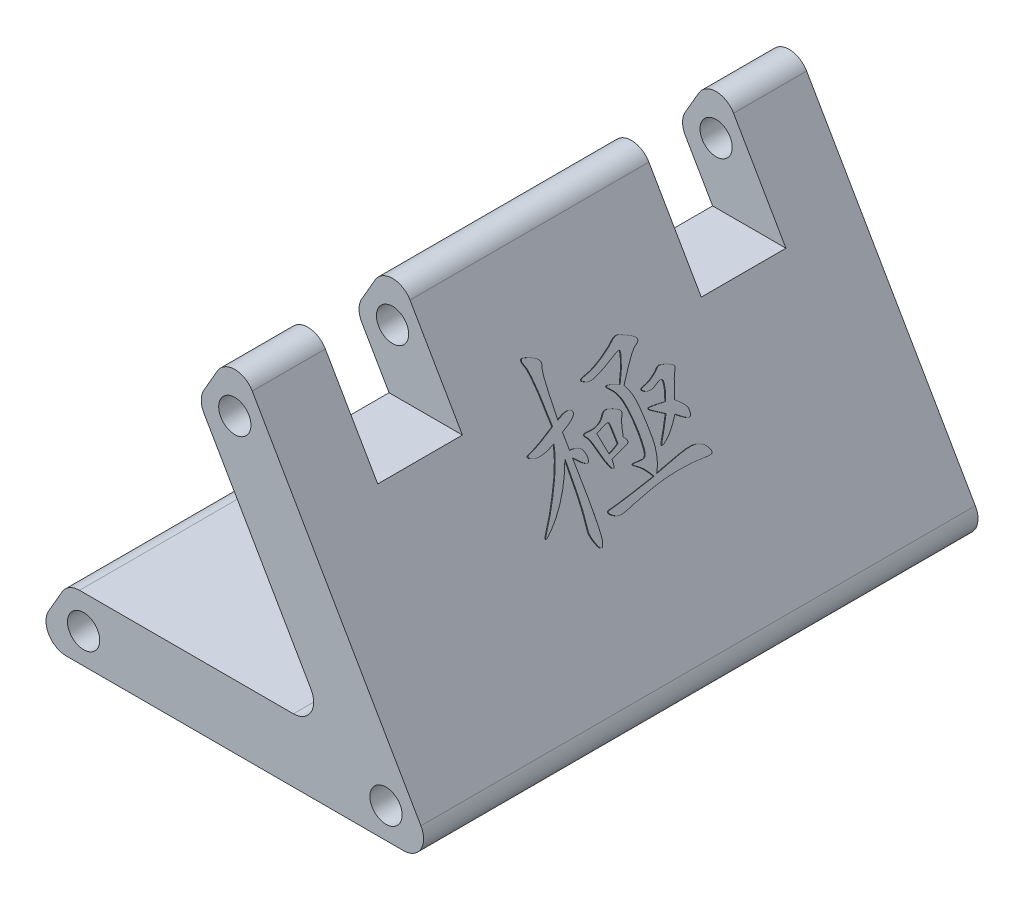
from build123d import *

# Parameters (mm, degrees)
SKETCH_1_R          = 1.6
EXTRUDE_1_DEPTH     = 27.5
FILLET_1_R          = 2
CUT_EXTRUDE_1_DEPTH = 66.5
FILLET_2_R          = 2
EXTRUDE_2_DEPTH     = 0.1
SKETCH_4_W          = 8.4
SKETCH_4_H          = 20
CUT_EXTRUDE_2_DEPTH = 25


with BuildPart() as part:
    # 草图1 → 凸台-拉伸1 (new body, symmetric)
    with BuildSketch(Plane.XY):
        Polygon((20.196152423, -28.980762114), (0, 6), (-20.196152423, -28.980762114), align=None)
        Circle(SKETCH_1_R, mode=Mode.SUBTRACT)
        with Locations((-15, -25.980762114)):
            Circle(SKETCH_1_R, mode=Mode.SUBTRACT)
        with Locations((15, -25.980762114)):
            Circle(SKETCH_1_R, mode=Mode.SUBTRACT)
    extrude(amount=EXTRUDE_1_DEPTH, both=True)

    # 圆角1
    fillet_1_edges = [part.edges().sort_by_distance(p)[0] for p in [
        (-20.196152423, -28.980762114, 0),
        (0, 6, 0),
        (20.196152423, -28.980762114, 0),
    ]]
    fillet(fillet_1_edges, radius=FILLET_1_R)

    # 草图2 → 切除-拉伸1 (cut, symmetric)
    with BuildSketch(Plane(origin=(0, 0, -27.5), x_dir=(-1, 0, 0), z_dir=(0, 0, -1))):
        Polygon((3.637306696, -0.3), (-9.284232335, -22.680762114), (16.558845727, -22.680762114), align=None)
    extrude(amount=CUT_EXTRUDE_1_DEPTH, both=True, mode=Mode.SUBTRACT)

    # 圆角2
    fillet_2_edges = [part.edges().sort_by_distance(p)[0] for p in [
        (-3.637306696, -0.3, 0),
        (-16.558845727, -22.680762114, 0),
        (9.284232335, -22.680762114, 0),
    ]]
    fillet(fillet_2_edges, radius=FILLET_2_R)

    # 草图3 → 凸台-拉伸2 (add, symmetric)
    with BuildSketch(Plane(origin=(2.598076211, 1.5, 0), x_dir=(0, 0, -1), z_dir=(0.866025404, 0.5, 0))):
        with BuildLine():
            add(Edge.make_bspline(
                [(2.736842105, -11.381173615), (2.801991454, -11.497126082), (2.929682208, -11.724389415), (3.085120059, -12.075523331), (3.193718681, -12.429488031), (3.256485862, -12.730112981), (3.29011482, -12.987916168), (3.313186965, -13.214143189), (3.333687441, -13.474998217), (3.351654391, -13.769617528), (3.366127131, -14.098938608), (3.383626882, -14.460960907), (3.391125932, -14.85791078), (3.40520759, -15.278842295), (3.401922108, -15.705724223), (3.371922554, -16.119384477), (3.311446119, -16.509218732), (3.22833647, -16.878342951), (3.108315326, -17.221984812), (2.97041173, -17.545865882), (2.800400711, -17.846024644), (2.66432259, -18.027536725), (2.596491228, -18.11801572)],
                knots=[0, 0, 0, 0, 0.000398891, 0.000781813, 0.001149279, 0.001507624, 0.001701705, 0.001929032, 0.002189772, 0.002486626, 0.002814483, 0.003178689, 0.003573888, 0.004005462, 0.00444214, 0.004853979, 0.005248399, 0.005624774, 0.005987242, 0.006338764, 0.006679839, 0.007018839, 0.007018839, 0.007018839, 0.007018839], degree=3))
            add(Edge.make_bspline(
                [(2.596491228, -18.11801572), (2.853723167, -18.073369607), (3.344469328, -17.988193914), (4.046248622, -17.873796403), (4.677787517, -17.777021229), (5.160558019, -17.709898794), (5.510465418, -17.664854849), (5.745500236, -17.644485104), (5.962150749, -17.631251498), (6.159835357, -17.624789808), (6.339436685, -17.630335574), (6.499889707, -17.643120636), (6.6430527, -17.661674597), (6.805396405, -17.704877093), (6.987636527, -17.770881177), (7.184213208, -17.876630845), (7.361237511, -18.000934423), (7.508902952, -18.148444398), (7.629703359, -18.301723709), (7.720700796, -18.452609383), (7.777439867, -18.60188845), (7.785557085, -18.701521307), (7.789473684, -18.749594667)],
                knots=[0, 0, 0, 0, 0.000783228, 0.00149424, 0.002133098, 0.00269989, 0.002956504, 0.003191344, 0.00340746, 0.003607657, 0.003784472, 0.003946138, 0.004090593, 0.004216669, 0.004449385, 0.004670308, 0.004884524, 0.005095883, 0.005293977, 0.005468717, 0.00562327, 0.005767373, 0.005767373, 0.005767373, 0.005767373], degree=3))
            add(Edge.make_bspline(
                [(7.789473684, -18.749594667), (7.785975484, -18.766222387), (7.778416926, -18.802149885), (7.724299236, -18.839168236), (7.648908836, -18.864093288), (7.542635128, -18.873225444), (7.409197832, -18.879543713), (7.245764183, -18.869913791), (7.053732827, -18.847504464), (6.748181589, -18.807909918), (6.321522729, -18.749974838), (5.761877872, -18.709216123), (5.145600849, -18.682659521), (4.715650315, -18.680530512), (4.49122807, -18.679419229)],
                knots=[0, 0, 0, 0, 4.9314e-05, 0.000106553, 0.00018383, 0.000288602, 0.000423855, 0.000585187, 0.000778641, 0.001003983, 0.001509471, 0.00207002, 0.002686552, 0.003359762, 0.003359762, 0.003359762, 0.003359762], degree=3))
            add(Edge.make_bspline(
                [(4.49122807, -18.679419229), (4.265924864, -18.682040004), (3.809795623, -18.687345796), (3.116121084, -18.727463093), (2.405586922, -18.796215158), (1.806499715, -18.871507286), (1.333039295, -18.939984395), (0.996369129, -18.993363432), (0.679761984, -19.041226097), (0.383793524, -19.091774501), (0.108768487, -19.137226777), (-0.14501372, -19.184523926), (-0.377897351, -19.231409879), (-0.651183967, -19.288128695), (-0.950870391, -19.352215833), (-1.270047941, -19.38905987), (-1.531946812, -19.409004229), (-1.747892364, -19.38809461), (-1.933123425, -19.336747723), (-2.101801713, -19.250224728), (-2.268952645, -19.139514464), (-2.397434763, -19.026173266), (-2.4836505, -18.929927938), (-2.52480624, -18.865513298), (-2.539060715, -18.806485511), (-2.522260641, -18.751748373), (-2.468818811, -18.717221098), (-2.394316116, -18.697014554), (-2.293842533, -18.681076495), (-2.21796165, -18.680014412), (-2.175438596, -18.679419229)],
                knots=[0, 0, 0, 0, 0.000675888, 0.001368345, 0.002083695, 0.002817103, 0.003179525, 0.003518813, 0.003839725, 0.004140108, 0.004419556, 0.004675971, 0.004914522, 0.005132179, 0.005513458, 0.005832935, 0.006095764, 0.006299557, 0.006480563, 0.006668867, 0.006865661, 0.007081072, 0.007180587, 0.007252802, 0.007308365, 0.007357679, 0.007413302, 0.007489743, 0.007589732, 0.007717194, 0.007717194, 0.007717194, 0.007717194], degree=3))
            add(Edge.make_bspline(
                [(-2.175438596, -18.679419229), (-2.147713216, -18.678618123), (-2.083574816, -18.676764889), (-1.973456389, -18.671782131), (-1.837534815, -18.66057375), (-1.67470078, -18.647200399), (-1.486332698, -18.633627655), (-1.272073007, -18.606769029), (-1.030782853, -18.586000119), (-0.763145999, -18.556579951), (-0.469598981, -18.522352552), (-0.149066092, -18.485761979), (0.197698245, -18.447825113), (0.571035332, -18.403012029), (0.969440089, -18.353501851), (1.394770315, -18.301069982), (1.846373581, -18.247484583), (2.156403889, -18.208323662), (2.315789474, -18.188191158)],
                knots=[0, 0, 0, 0, 8.3211e-05, 0.000192497, 0.000330641, 0.000492307, 0.000682681, 0.000897086, 0.001139931, 0.001409159, 0.001704794, 0.002026546, 0.002376999, 0.002751286, 0.003154581, 0.00358141, 0.004036933, 0.004518888, 0.004518888, 0.004518888, 0.004518888], degree=3))
            add(Edge.make_bspline(
                [(2.315789474, -18.188191158), (2.235201176, -18.055623904), (2.081101101, -17.802130226), (1.819483938, -17.466074098), (1.553183261, -17.182768823), (1.317632044, -16.998768193), (1.147390475, -16.87903752), (1.054292788, -16.804369993), (0.996495182, -16.7441399), (0.959000838, -16.697119269), (0.968341377, -16.646303045), (1.024513843, -16.632417303), (1.09706398, -16.632969304), (1.235563137, -16.648700084), (1.415728403, -16.676796554), (1.622556552, -16.695850571), (1.80270064, -16.710378726), (1.913771824, -16.713205444), (1.964912281, -16.714506948)],
                knots=[0, 0, 0, 0, 0.000465063, 0.000889288, 0.001275303, 0.001628445, 0.001782845, 0.001900982, 0.001983705, 0.002037224, 0.0020719, 0.002117291, 0.002190112, 0.002297181, 0.002530593, 0.002739557, 0.002919365, 0.003072799, 0.003072799, 0.003072799, 0.003072799], degree=3))
            add(Edge.make_bspline(
                [(1.964912281, -16.714506948), (2.009804267, -16.71001934), (2.099949377, -16.701008023), (2.212660918, -16.606651136), (2.300240084, -16.469699956), (2.344498769, -16.318648037), (2.378638085, -16.173120497), (2.39784197, -16.037279254), (2.415803648, -15.882167641), (2.431916707, -15.708035614), (2.441276138, -15.513791458), (2.449057476, -15.299783889), (2.454204917, -15.065839447), (2.455479346, -14.903809756), (2.456140351, -14.819770106)],
                knots=[0, 0, 0, 0, 0.000132528, 0.000266122, 0.000421829, 0.000616622, 0.000733899, 0.000870642, 0.001027645, 0.001202481, 0.001395094, 0.001610959, 0.001844935, 0.00209706, 0.00209706, 0.00209706, 0.00209706], degree=3))
            add(Edge.make_bspline(
                [(2.456140351, -14.819770106), (2.454455783, -14.635175765), (2.451139057, -14.271729962), (2.415648542, -13.735907981), (2.362130041, -13.217962702), (2.286590132, -12.723411001), (2.184486463, -12.26227825), (2.030838874, -11.852355675), (1.834447433, -11.496553873), (1.627858097, -11.255379139), (1.467614739, -11.095030595), (1.37967094, -10.993325707), (1.322491322, -10.909897508), (1.287320778, -10.849366499), (1.28454722, -10.79372499), (1.329257548, -10.765194645), (1.393990309, -10.770591358), (1.517914332, -10.792780711), (1.70127659, -10.849708001), (1.938123663, -10.934014775), (2.19296252, -11.042420104), (2.365561727, -11.126514999), (2.456140351, -11.170647299)],
                knots=[0, 0, 0, 0, 0.000553704, 0.001090182, 0.001610272, 0.002115353, 0.002590695, 0.003024182, 0.003424577, 0.003802948, 0.003972069, 0.004104852, 0.004205782, 0.0042744, 0.004316066, 0.004355053, 0.004414888, 0.004507184, 0.004734243, 0.004988277, 0.005261985, 0.005564251, 0.005564251, 0.005564251, 0.005564251], degree=3))
            add(Edge.make_bspline(
                [(2.456140351, -11.170647299), (2.534044382, -11.056817564), (2.685811723, -10.835062208), (2.892979171, -10.504325767), (3.073416264, -10.186067563), (3.225036981, -9.886748704), (3.344278162, -9.616784058), (3.433945315, -9.39144546), (3.492325763, -9.213673235), (3.503940381, -9.108948455), (3.50877193, -9.065384141)],
                knots=[0, 0, 0, 0, 0.000413778, 0.000806094, 0.001170385, 0.001510955, 0.001812326, 0.002055101, 0.002239325, 0.002370547, 0.002370547, 0.002370547, 0.002370547], degree=3))
            add(Edge.make_bspline(
                [(3.50877193, -9.065384141), (3.506306125, -9.049644632), (3.501362765, -9.018090605), (3.454362522, -8.984932657), (3.386578694, -8.980481266), (3.297516094, -8.986262309), (3.183410754, -9.008951716), (3.045013615, -9.048729985), (2.880467356, -9.104016546), (2.501963711, -9.24678581), (1.930349285, -9.463826004), (1.298134346, -9.657906761), (0.835288948, -9.788445462), (0.544391506, -9.843016806), (0.307036104, -9.880801343), (0.11208528, -9.879610737), (-0.053336801, -9.848935209), (-0.205162793, -9.795996215), (-0.352124077, -9.721542215), (-0.46618343, -9.647672742), (-0.543855587, -9.585774808), (-0.57365535, -9.535453971), (-0.567770204, -9.481849763), (-0.520380617, -9.443414285), (-0.44926341, -9.414214062), (-0.35035741, -9.386256765), (-0.22061869, -9.364008087), (-0.00041358, -9.338237998), (0.313315575, -9.295435098), (0.717959194, -9.198690776), (1.15589734, -9.061475912), (1.613783614, -8.895654898), (2.056628054, -8.710708771), (2.457693649, -8.533707677), (2.796823091, -8.363801835), (3.073207799, -8.199742995), (3.302106622, -8.05626023), (3.511771881, -7.976831392), (3.697669599, -7.942457788), (3.867168224, -7.974224814), (4.030821698, -8.049732407), (4.225007872, -8.139627042), (4.451916285, -8.260602346), (4.699308791, -8.396906876), (4.934097264, -8.535696734), (5.119149013, -8.67256416), (5.243629288, -8.794526461), (5.30783066, -8.916845227), (5.291449976, -9.039385844), (5.204922471, -9.14389585), (5.060780839, -9.234456109), (4.895192498, -9.300166288), (4.722803761, -9.388717029), (4.55443195, -9.519342268), (4.343204056, -9.695379004), (4.097426819, -9.930387323), (3.809044003, -10.214752914), (3.485763687, -10.556137437), (3.123546742, -10.950234479), (2.870816269, -11.23187437), (2.736842105, -11.381173615)],
                knots=[0, 0, 0, 0, 4.6056e-05, 9.2331e-05, 0.000158135, 0.000246657, 0.000360336, 0.000506001, 0.000678601, 0.000880896, 0.001719601, 0.002512055, 0.002864479, 0.00316114, 0.003399705, 0.003584258, 0.003742803, 0.003902261, 0.004064989, 0.004235839, 0.004309444, 0.00436175, 0.004403659, 0.004458794, 0.004533221, 0.004636041, 0.004765527, 0.004928006, 0.005301091, 0.005714673, 0.006174242, 0.006677419, 0.007175049, 0.007613648, 0.007992581, 0.008311751, 0.008578358, 0.008800424, 0.008981635, 0.009137168, 0.009308511, 0.009521272, 0.009779355, 0.010079513, 0.010368807, 0.01059701, 0.010768017, 0.010890202, 0.010994975, 0.011117656, 0.011284181, 0.011501652, 0.011651635, 0.011863744, 0.012138622, 0.012476963, 0.012883128, 0.013353743, 0.013887171, 0.014488955, 0.014488955, 0.014488955, 0.014488955], degree=3))
        make_face()
        with BuildLine():
            add(Edge.make_bspline(
                [(-3.719298246, -11.170647299), (-3.646765375, -11.14310885), (-3.507879924, -11.090378414), (-3.305657252, -11.025747194), (-3.121044857, -10.97553713), (-2.954472415, -10.941191525), (-2.804908681, -10.921355753), (-2.67271089, -10.919541807), (-2.556187397, -10.92614513), (-2.435569869, -10.964841855), (-2.318898455, -11.021198987), (-2.226198575, -11.126742326), (-2.21846925, -11.260819899), (-2.269065728, -11.370213756), (-2.34514505, -11.463986214), (-2.446073716, -11.535437363), (-2.572093516, -11.62160398), (-2.738793538, -11.699869611), (-2.933216937, -11.793994511), (-3.165514297, -11.884767028), (-3.430425325, -11.984109414), (-3.619479497, -12.048781679), (-3.719298246, -12.082928001)],
                knots=[0, 0, 0, 0, 0.000232717, 0.000445604, 0.000636633, 0.000806372, 0.000955633, 0.001088212, 0.001203043, 0.00130337, 0.001466202, 0.001588387, 0.001703219, 0.00184657, 0.001940749, 0.002062933, 0.002215041, 0.002398696, 0.002613809, 0.002863335, 0.003146242, 0.003462702, 0.003462702, 0.003462702, 0.003462702], degree=3))
            Line((-3.719298246, -12.082928001), (-3.719298246, -13.486436772))
            add(Edge.make_bspline(
                [(-3.719298246, -13.486436772), (-3.646366691, -13.492999619), (-3.507569874, -13.505489443), (-3.312146948, -13.542413416), (-3.137966078, -13.589023679), (-2.984625629, -13.646207201), (-2.855057515, -13.721724829), (-2.743831286, -13.803415872), (-2.655221848, -13.901166519), (-2.576642018, -14.046425548), (-2.509206157, -14.228889608), (-2.467505064, -14.446870705), (-2.469917715, -14.658854055), (-2.505108954, -14.819370993), (-2.565521204, -14.937996039), (-2.665312402, -14.957663507), (-2.776878536, -14.92248545), (-2.910852182, -14.838581983), (-3.074756528, -14.712855314), (-3.264381436, -14.534684561), (-3.483563034, -14.309157148), (-3.636726758, -14.139372311), (-3.719298246, -14.047840281)],
                knots=[0, 0, 0, 0, 0.000219573, 0.000417872, 0.000595677, 0.000760263, 0.000906945, 0.001044181, 0.001173039, 0.001298767, 0.00153726, 0.001753922, 0.001961866, 0.002165476, 0.002253424, 0.002334121, 0.002443808, 0.00259984, 0.002805694, 0.003063227, 0.003379355, 0.00374913, 0.00374913, 0.00374913, 0.00374913], degree=3))
            add(Edge.make_bspline(
                [(-3.719298246, -14.047840281), (-3.716535951, -14.269627552), (-3.711151725, -14.701932136), (-3.706017592, -15.331783727), (-3.703313478, -15.926113009), (-3.703197967, -16.483191716), (-3.705837788, -17.004747462), (-3.710504472, -17.48993068), (-3.71951457, -17.93867112), (-3.725283205, -18.351161286), (-3.739270236, -18.72713451), (-3.753860177, -19.067699253), (-3.773599409, -19.372512349), (-3.788766863, -19.641510862), (-3.814307003, -19.873388402), (-3.835168398, -20.069834007), (-3.863766263, -20.229260539), (-3.89974126, -20.386437974), (-3.94844462, -20.536036941), (-4.016441227, -20.669409596), (-4.079483611, -20.764390815), (-4.166681789, -20.802498963), (-4.257041723, -20.773867912), (-4.33354269, -20.689715554), (-4.417627876, -20.565106148), (-4.521805895, -20.33458207), (-4.641621584, -20.035540409), (-4.730647964, -19.687859489), (-4.773181843, -19.378976607), (-4.742031308, -19.094707935), (-4.679315865, -18.805327147), (-4.627027871, -18.467015299), (-4.57640279, -18.067302918), (-4.532933097, -17.689514239), (-4.499043232, -17.334182101), (-4.473134616, -17.003233399), (-4.45094791, -16.614080019), (-4.426764977, -16.168836386), (-4.407363225, -15.666232614), (-4.385506078, -15.107491416), (-4.368469688, -14.491433303), (-4.3569121, -14.061702228), (-4.350877193, -13.837313965)],
                knots=[0, 0, 0, 0, 0.000665413, 0.001297013, 0.001889611, 0.002448416, 0.00296824, 0.003454298, 0.003904008, 0.004314739, 0.004691831, 0.005032668, 0.005337306, 0.005608223, 0.005840722, 0.006037052, 0.006200712, 0.00632617, 0.006520963, 0.006669749, 0.006776912, 0.006855101, 0.006935798, 0.007042456, 0.007190239, 0.00738669, 0.007798897, 0.008155693, 0.008461658, 0.008727795, 0.00900816, 0.009350422, 0.009754043, 0.010217009, 0.010491149, 0.010824846, 0.011212816, 0.011660471, 0.012162526, 0.012721718, 0.013337971, 0.014011381, 0.014011381, 0.014011381, 0.014011381], degree=3))
            add(Edge.make_bspline(
                [(-4.350877193, -13.837313965), (-4.464832817, -14.049924), (-4.683326498, -14.457573462), (-5.031553044, -15.024694741), (-5.368699198, -15.530448202), (-5.707641464, -15.970800812), (-6.042307013, -16.359098037), (-6.369457435, -16.710014413), (-6.690709366, -17.027999914), (-7.009031996, -17.31004179), (-7.321938963, -17.558223833), (-7.623273983, -17.784299376), (-7.917714579, -17.979287042), (-8.150712175, -18.129074966), (-8.311880454, -18.20275346), (-8.387605435, -18.246306253), (-8.449375242, -18.215956796), (-8.409850324, -18.139622513), (-8.357294456, -18.054634808), (-8.25002931, -17.919805686), (-8.109364572, -17.748529959), (-7.843739483, -17.467234943), (-7.483543833, -17.05100448), (-7.033457941, -16.490861624), (-6.572889657, -15.85529027), (-6.180581485, -15.287985476), (-5.869749346, -14.813103819), (-5.654550387, -14.457323043), (-5.458700979, -14.110577839), (-5.282021677, -13.772468525), (-5.122398755, -13.444223411), (-4.987584472, -13.122417575), (-4.869613782, -12.811429226), (-4.803958107, -12.604785826), (-4.771929825, -12.503980632)],
                knots=[0, 0, 0, 0, 0.000723519, 0.001387244, 0.001995659, 0.002546182, 0.003053058, 0.003533017, 0.00398514, 0.004408624, 0.004808039, 0.005183353, 0.005537298, 0.005870711, 0.006004382, 0.006080068, 0.006116176, 0.006172283, 0.006281938, 0.006448807, 0.006672102, 0.006953585, 0.007605672, 0.008324944, 0.00910784, 0.009959993, 0.010393979, 0.010810304, 0.011207157, 0.011588471, 0.011954657, 0.01230174, 0.01263484, 0.012952099, 0.012952099, 0.012952099, 0.012952099], degree=3))
            add(Edge.make_bspline(
                [(-4.771929825, -12.503980632), (-4.890298556, -12.541464385), (-5.11786022, -12.613526196), (-5.449876389, -12.699572897), (-5.758655656, -12.761431589), (-6.043771474, -12.794802566), (-6.304623668, -12.807557502), (-6.541920184, -12.792628327), (-6.755454464, -12.752394957), (-6.94044614, -12.687610933), (-7.09068421, -12.613953662), (-7.20293297, -12.543733615), (-7.279727626, -12.486015217), (-7.314004214, -12.420340265), (-7.290790733, -12.356964066), (-7.220955483, -12.316852825), (-7.117346449, -12.281408209), (-6.969522709, -12.258020639), (-6.781151251, -12.222843138), (-6.554097658, -12.160094713), (-6.2851381, -12.082592994), (-5.976795726, -11.983147985), (-5.627270514, -11.863601727), (-5.238658953, -11.718827359), (-4.807141271, -11.559276976), (-4.507502058, -11.442312363), (-4.350877193, -11.381173615)],
                knots=[0, 0, 0, 0, 0.000372433, 0.000715994, 0.001028459, 0.001316348, 0.001576465, 0.001810903, 0.002028047, 0.002226142, 0.002397011, 0.002528977, 0.002622869, 0.002684648, 0.002733963, 0.002808298, 0.002915996, 0.003064326, 0.003254966, 0.003491369, 0.003770199, 0.004094877, 0.004463105, 0.00487835, 0.00533891, 0.005843301, 0.005843301, 0.005843301, 0.005843301], degree=3))
            add(Edge.make_bspline(
                [(-4.350877193, -11.381173615), (-4.351889362, -11.21570009), (-4.35386071, -10.893416332), (-4.354316265, -10.422933919), (-4.364398185, -9.978541106), (-4.369932116, -9.559991135), (-4.383982654, -9.167553437), (-4.399135799, -8.801049408), (-4.417402518, -8.45968327), (-4.437718238, -8.144264853), (-4.461274858, -7.854011565), (-4.486591646, -7.590516938), (-4.515385703, -7.352230069), (-4.545864231, -7.139765723), (-4.579616112, -6.952519283), (-4.614382743, -6.790501198), (-4.656077225, -6.655459656), (-4.709900532, -6.516009297), (-4.770846762, -6.37796413), (-4.810141129, -6.234678538), (-4.819508738, -6.122524032), (-4.787387662, -6.034840181), (-4.709321282, -5.987935748), (-4.602690645, -5.990799775), (-4.468953481, -6.022223429), (-4.25734765, -6.107117064), (-3.999779763, -6.226351154), (-3.725938942, -6.366392417), (-3.518815242, -6.501875398), (-3.37261774, -6.631201864), (-3.281889335, -6.758806592), (-3.239862248, -6.887352239), (-3.239555864, -7.019573275), (-3.290899404, -7.121577521), (-3.337166404, -7.216149881), (-3.368152251, -7.314696243), (-3.403342517, -7.435437531), (-3.433642228, -7.581518239), (-3.460227328, -7.752840234), (-3.493095798, -7.947275947), (-3.520946624, -8.165797728), (-3.546041817, -8.407720993), (-3.572951928, -8.672682634), (-3.595235333, -8.961370758), (-3.618665746, -9.273255096), (-3.64284064, -9.608443595), (-3.662278147, -9.966393514), (-3.684389077, -10.347484337), (-3.70133863, -10.751319185), (-3.713212944, -11.028565293), (-3.719298246, -11.170647299)],
                knots=[0, 0, 0, 0, 0.000496433, 0.000966876, 0.001411388, 0.001829915, 0.002222592, 0.002589396, 0.002930362, 0.003248132, 0.003537578, 0.003803956, 0.004042195, 0.004257591, 0.004447751, 0.004612952, 0.004754358, 0.004871172, 0.005061333, 0.005206324, 0.005315516, 0.005394693, 0.005471838, 0.00557074, 0.005706342, 0.005883995, 0.006252681, 0.006558458, 0.006805714, 0.006993317, 0.0071411, 0.007269327, 0.007394111, 0.007525872, 0.007606108, 0.007710493, 0.007834734, 0.007983587, 0.008157493, 0.008354904, 0.008575092, 0.008818201, 0.009084579, 0.009374025, 0.009686792, 0.010022889, 0.010382166, 0.010762202, 0.011168068, 0.011594707, 0.011594707, 0.011594707, 0.011594707], degree=3))
        make_face()
        with BuildLine():
            add(Edge.make_bspline(
                [(1.052631579, -14.60924379), (1.088815299, -14.647612832), (1.154717767, -14.717495492), (1.235552705, -14.82111952), (1.284877018, -14.915035511), (1.30537681, -14.999761022), (1.288720392, -15.076023742), (1.236109349, -15.136750027), (1.153302107, -15.178997834), (1.045367978, -15.210864675), (0.912947703, -15.236466524), (0.760200387, -15.270004424), (0.588696301, -15.313709649), (0.39619813, -15.355278212), (0.185876981, -15.410005475), (-0.046380437, -15.462424683), (-0.297181403, -15.525790491), (-0.471290807, -15.569221578), (-0.561403509, -15.59169993)],
                knots=[0, 0, 0, 0, 0.000158225, 0.000288179, 0.000392791, 0.000474858, 0.00054421, 0.00061809, 0.000707712, 0.000819503, 0.000955104, 0.001112129, 0.001288638, 0.00148598, 0.001702829, 0.0019405, 0.002200214, 0.002478839, 0.002478839, 0.002478839, 0.002478839], degree=3))
            add(Edge.make_bspline(
                [(-0.561403509, -15.59169993), (-0.563236756, -15.656684535), (-0.566618169, -15.776548246), (-0.582151464, -15.942713485), (-0.616008635, -16.078105503), (-0.652006024, -16.170857663), (-0.691494541, -16.221430588), (-0.731171654, -16.236647245), (-0.772164269, -16.213999158), (-0.814360932, -16.176309984), (-0.857287354, -16.112711167), (-0.909139316, -16.031490408), (-0.963679051, -15.924862531), (-1.044380881, -15.748341392), (-1.143735669, -15.494346821), (-1.261522493, -15.161126623), (-1.372712422, -14.79232373), (-1.471804031, -14.403254426), (-1.571285771, -14.028259112), (-1.690850674, -13.705032961), (-1.81386172, -13.443353547), (-1.932739442, -13.276740115), (-2.020869782, -13.177982037), (-2.051603282, -13.114753965), (-2.060180485, -13.057597316), (-2.02600225, -13.013451305), (-1.965558415, -12.994205494), (-1.884150334, -12.981403133), (-1.775708491, -12.984041276), (-1.599478479, -12.999783506), (-1.370178568, -13.019881912), (-1.102817878, -13.018890455), (-0.857367581, -12.988566), (-0.634762909, -12.930054065), (-0.432628153, -12.853951121), (-0.256636096, -12.752175586), (-0.094911898, -12.64316492), (0.029683935, -12.506677518), (0.149995994, -12.384372761), (0.280997923, -12.295984036), (0.421947137, -12.256261596), (0.569145987, -12.254695562), (0.73110418, -12.290799389), (0.916791479, -12.358303804), (1.133920735, -12.452937596), (1.326724348, -12.551651153), (1.4839494, -12.63744227), (1.577043876, -12.714541837), (1.651357684, -12.788175552), (1.69485639, -12.869977969), (1.714077234, -12.952582942), (1.709010606, -13.039068033), (1.672535817, -13.125171564), (1.610646219, -13.210746062), (1.538550895, -13.307941178), (1.468920551, -13.429372883), (1.39969391, -13.572185269), (1.329184067, -13.736895836), (1.260021333, -13.923708558), (1.189526603, -14.132502848), (1.119913319, -14.363232433), (1.075644095, -14.525100005), (1.052631579, -14.60924379)],
                knots=[0, 0, 0, 0, 0.000195088, 0.000359838, 0.00049915, 0.000613155, 0.000655465, 0.000688342, 0.000730331, 0.000785589, 0.000859924, 0.000958003, 0.001075424, 0.001218468, 0.001540388, 0.001893032, 0.002278654, 0.002695368, 0.003097724, 0.003441472, 0.003728575, 0.003961524, 0.004054074, 0.004122692, 0.004172143, 0.00421686, 0.004276242, 0.004357855, 0.004464418, 0.00459997, 0.004889217, 0.005154337, 0.005400634, 0.005628837, 0.00584362, 0.006046082, 0.00623794, 0.006425399, 0.006598195, 0.006752485, 0.006893149, 0.007030925, 0.007189959, 0.007388053, 0.007623195, 0.007899837, 0.008038469, 0.008158618, 0.008261603, 0.008349972, 0.008432572, 0.008513312, 0.008605497, 0.00870858, 0.008829737, 0.008968369, 0.009127615, 0.009305762, 0.009505622, 0.009725072, 0.009966801, 0.010228497, 0.010228497, 0.010228497, 0.010228497], degree=3))
        make_face()
        with BuildLine():
            add(Edge.make_bspline(
                [(-0.98245614, -13.416261334), (-0.948682808, -13.5930024), (-0.884931729, -13.926621641), (-0.794902399, -14.396545484), (-0.71241574, -14.80478224), (-0.657022803, -15.055489123), (-0.631578947, -15.170647299)],
                knots=[0, 0, 0, 0, 0.000539817, 0.001018967, 0.001435414, 0.001789215, 0.001789215, 0.001789215, 0.001789215], degree=3))
            add(Edge.make_bspline(
                [(-0.631578947, -15.170647299), (-0.565586071, -15.154758613), (-0.417776127, -15.11917135), (-0.176172237, -15.045810465), (0.107904953, -14.94200818), (0.311193472, -14.862653937), (0.421052632, -14.819770106)],
                knots=[0, 0, 0, 0, 0.00020361, 0.000456043, 0.000756932, 0.001110733, 0.001110733, 0.001110733, 0.001110733], degree=3))
            add(Edge.make_bspline(
                [(0.421052632, -14.819770106), (0.421307284, -14.725335208), (0.421793237, -14.545124788), (0.41853673, -14.28955463), (0.415889391, -14.062565838), (0.413951011, -13.864150057), (0.409343985, -13.694253632), (0.40093458, -13.552283175), (0.393545208, -13.439448313), (0.384564934, -13.333079261), (0.366868026, -13.230306503), (0.293269362, -13.145558469), (0.185987113, -13.11276408), (0.052198365, -13.137162244), (-0.120729585, -13.18614809), (-0.354343512, -13.243549752), (-0.646773929, -13.326656173), (-0.8636604, -13.384550653), (-0.98245614, -13.416261334)],
                knots=[0, 0, 0, 0, 0.000283301, 0.000540624, 0.00076676, 0.000964308, 0.001135926, 0.001276494, 0.001391119, 0.001474655, 0.001598214, 0.001695775, 0.001794404, 0.001919835, 0.002096974, 0.002335893, 0.002640441, 0.003009274, 0.003009274, 0.003009274, 0.003009274], degree=3))
        make_face(mode=Mode.SUBTRACT)
        with BuildLine():
            add(Edge.make_bspline(
                [(6.385964912, -14.11801572), (6.451957025, -14.175016527), (6.577353184, -14.283327686), (6.753319731, -14.440053003), (6.900050226, -14.592095817), (7.020625788, -14.734832155), (7.123413359, -14.863274315), (7.192942599, -14.987103109), (7.243606011, -15.098665716), (7.268587104, -15.23106996), (7.27095948, -15.373720013), (7.254464821, -15.524716512), (7.203527157, -15.644318006), (7.141446251, -15.728449925), (7.057771263, -15.76115729), (6.971897369, -15.737881324), (6.865001977, -15.696161943), (6.733793376, -15.620594959), (6.576139237, -15.518543612), (6.396373315, -15.381603434), (6.187391704, -15.218274578), (6.042453261, -15.09581264), (5.964912281, -15.030296422)],
                knots=[0, 0, 0, 0, 0.000261619, 0.00049712, 0.000706665, 0.0008947, 0.001057926, 0.001198806, 0.001319963, 0.001423438, 0.001600253, 0.00174728, 0.001874237, 0.001988419, 0.002049263, 0.002130876, 0.002245265, 0.002396482, 0.002582476, 0.002809119, 0.00307378, 0.003378273, 0.003378273, 0.003378273, 0.003378273], degree=3))
            add(Edge.make_bspline(
                [(5.964912281, -15.030296422), (5.839173325, -15.174729837), (5.597061088, -15.452838533), (5.208091655, -15.816202155), (4.822736839, -16.123393517), (4.497639555, -16.32393242), (4.263552575, -16.449422494), (4.125494674, -16.50866523), (4.03248732, -16.538784782), (3.958054783, -16.550663072), (3.923667508, -16.496789735), (3.960599305, -16.426396549), (4.016301779, -16.334917857), (4.152965902, -16.160149474), (4.362824635, -15.90227052), (4.635663169, -15.54040077), (4.941397585, -15.128807741), (5.151863004, -14.834859921), (5.263157895, -14.679419229)],
                knots=[0, 0, 0, 0, 0.000574158, 0.001105549, 0.001594289, 0.002050798, 0.002247265, 0.002394016, 0.002494343, 0.002554178, 0.002591663, 0.002659139, 0.002768795, 0.00292474, 0.00331685, 0.003771185, 0.004282176, 0.004855639, 0.004855639, 0.004855639, 0.004855639], degree=3))
            add(Edge.make_bspline(
                [(5.263157895, -14.679419229), (5.190500295, -14.629866413), (5.039430456, -14.526836091), (4.801022527, -14.369303609), (4.548908866, -14.193281669), (4.327627066, -14.049517088), (4.167833792, -13.932532851), (4.079275227, -13.857233114), (4.027621693, -13.799151657), (3.998074661, -13.743021546), (4.034065664, -13.697632971), (4.100741506, -13.685582236), (4.195844594, -13.685146011), (4.480736711, -13.71254463), (4.95747364, -13.78472505), (5.388986791, -13.865409704), (5.614035088, -13.907489404)],
                knots=[0, 0, 0, 0, 0.000263843, 0.000548583, 0.000857131, 0.00118657, 0.001338878, 0.00145306, 0.001530599, 0.001579913, 0.001621008, 0.001681013, 0.001777214, 0.001907584, 0.002537594, 0.00322431, 0.00322431, 0.00322431, 0.00322431], degree=3))
            add(Edge.make_bspline(
                [(5.614035088, -13.907489404), (5.678101471, -13.775716212), (5.796764543, -13.531647309), (5.936835551, -13.183018481), (6.027598502, -12.882129499), (6.069703178, -12.662539538), (6.072071903, -12.51501489), (6.046541252, -12.431998308), (5.99542952, -12.36979991), (5.916574978, -12.339458535), (5.817486186, -12.33687177), (5.699003248, -12.361339493), (5.556362632, -12.402660762), (5.40109779, -12.471530709), (5.237752165, -12.542328232), (5.072286348, -12.590135418), (4.916486849, -12.626710269), (4.76606506, -12.639295475), (4.623727205, -12.634764266), (4.487567546, -12.611696987), (4.361198918, -12.56685387), (4.246110966, -12.508379035), (4.152698583, -12.443611386), (4.080966657, -12.384791338), (4.041342171, -12.330079316), (4.026069327, -12.273837158), (4.06256572, -12.228884185), (4.120531879, -12.197323661), (4.206932194, -12.16830843), (4.36240693, -12.146654687), (4.573107795, -12.113411145), (4.823509039, -12.049004757), (5.06592936, -11.972757186), (5.293809205, -11.876233768), (5.50199514, -11.774539357), (5.684264801, -11.674880991), (5.839447341, -11.585324895), (5.959886612, -11.488291613), (6.085826681, -11.406751689), (6.247367371, -11.39387307), (6.43262812, -11.416136109), (6.634344069, -11.486860792), (6.838475857, -11.572408593), (7.029794241, -11.655337727), (7.191502755, -11.745256819), (7.325479802, -11.829504585), (7.431637113, -11.919009608), (7.468852493, -12.044146109), (7.428072948, -12.177059469), (7.325561515, -12.300719869), (7.208780224, -12.445654312), (7.101551377, -12.621382324), (6.998813952, -12.817145567), (6.907990097, -13.03804184), (6.810837574, -13.280033241), (6.689588231, -13.540725939), (6.54689265, -13.823009412), (6.441100257, -14.016943807), (6.385964912, -14.11801572)],
                knots=[0, 0, 0, 0, 0.000439492, 0.000814023, 0.001125708, 0.001381226, 0.001482624, 0.001564815, 0.001636702, 0.001715878, 0.00180959, 0.001930943, 0.002077325, 0.002254464, 0.002439803, 0.00261083, 0.002770394, 0.002919111, 0.003062155, 0.003196757, 0.003331559, 0.00346291, 0.003582581, 0.003672804, 0.003738402, 0.003785831, 0.003832686, 0.003896879, 0.003984827, 0.00410362, 0.004367258, 0.004624449, 0.00487843, 0.005128942, 0.005366073, 0.005573088, 0.005752727, 0.005901398, 0.006038733, 0.006193482, 0.006374021, 0.006597603, 0.006830726, 0.007038945, 0.007222728, 0.007384207, 0.007516531, 0.007627564, 0.00775364, 0.007915891, 0.00810669, 0.008312215, 0.008531927, 0.008769456, 0.009028166, 0.009314255, 0.009631578, 0.009976954, 0.009976954, 0.009976954, 0.009976954], degree=3))
        make_face()
    extrude(amount=EXTRUDE_2_DEPTH, both=True)

    # 草图4 → 切除-拉伸2 (cut, symmetric)
    with BuildSketch(Plane(origin=(0, 0, 0), x_dir=(0, 0, -1), z_dir=(1, 0, 0))):
        with Locations((-16.05, 4)):
            Rectangle(SKETCH_4_W, SKETCH_4_H)
        with Locations((16.05, 4)):
            Rectangle(SKETCH_4_W, SKETCH_4_H)
    extrude(amount=CUT_EXTRUDE_2_DEPTH, both=True, mode=Mode.SUBTRACT)


solid = part.part
